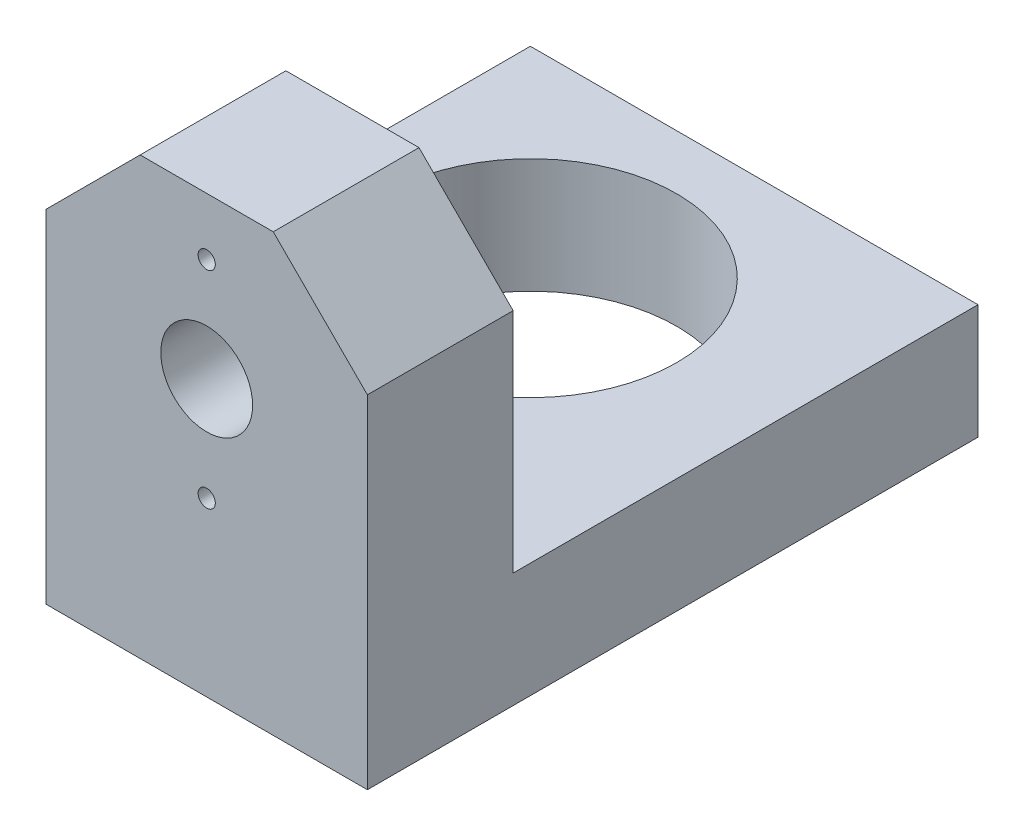
from build123d import *

# Parameters (mm, degrees)
SKETCH1_R           = 4
SKETCH1_R_2         = 0.75
BOSS_EXTRUDE1_DEPTH = 12.7
SKETCH2_R           = 12.75
BOSS_EXTRUDE2_DEPTH = 10


with BuildPart() as part:
    # Sketch1 → Boss-Extrude1 (new body)
    with BuildSketch(Plane.XY):
        Polygon((-5.798989873, 14), (5.798989873, 14), (14, 5.798989873), (14, -5.798989873), (14, -14), (5.798989873, -14), (-5.798989873, -14), (-14, -14), (-14, -5.798989873), (-14, 5.798989873), align=None)
        Circle(SKETCH1_R, mode=Mode.SUBTRACT)
        with Locations((0, 9)):
            Circle(SKETCH1_R_2, mode=Mode.SUBTRACT)
        with Locations((0, -9)):
            Circle(SKETCH1_R_2, mode=Mode.SUBTRACT)
    extrude(amount=BOSS_EXTRUDE1_DEPTH)

    # Sketch2 → Boss-Extrude2 (add)
    with BuildSketch(Plane.XZ.offset(14)):
        Polygon((14, 12.7), (-14, 12.7), (-14, 0), (-25, -11), (-25, -40.5), (14, -40.5), align=None)
        with Locations((-7.5, -23)):
            Circle(SKETCH2_R, mode=Mode.SUBTRACT)
    extrude(amount=BOSS_EXTRUDE2_DEPTH)


solid = part.part
